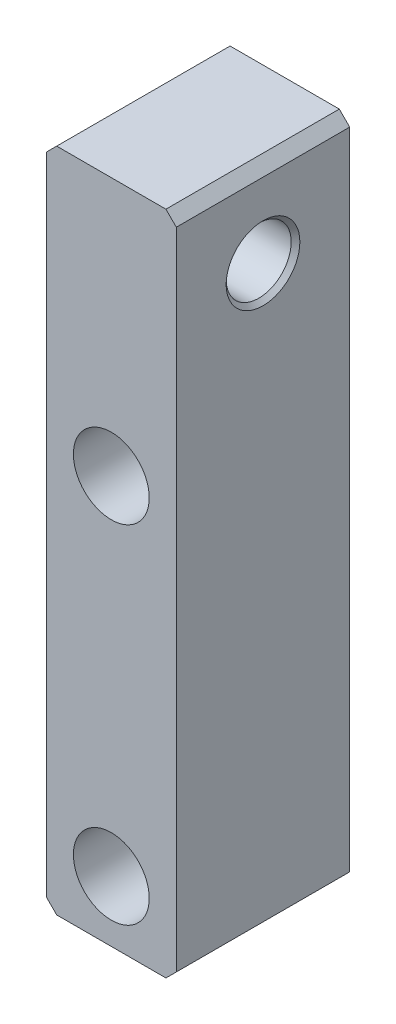
from build123d import *

# Parameters (mm, degrees)
BOSS_EXTRUDE1_DEPTH                              = 12.7
CBORE_FOR_1_4_SOCKET_HEAD_CAP_SCREW1_D           = 6.7564
CBORE_FOR_1_4_SOCKET_HEAD_CAP_SCREW1_DEPTH       = 25.4
CBORE_FOR_1_4_SOCKET_HEAD_CAP_SCREW1_CBORE_D     = 11.1125
CBORE_FOR_1_4_SOCKET_HEAD_CAP_SCREW1_CBORE_DEPTH = 9.652


with BuildPart() as part:
    # Sketch6 → Boss-Extrude1 (new body, symmetric)
    with BuildSketch(Plane.XY):
        Polygon((-8.001, 88.646), (8.001, 88.646), (9.525, 87.122), (9.525, -7.366), (8.001, -8.89), (-8.001, -8.89), (-9.525, -7.366), (-9.525, 87.122), align=None)
    extrude(amount=BOSS_EXTRUDE1_DEPTH, both=True)

    # Sketch11 → 3/8-16 Tapped Hole1 (revolve, cut)
    with BuildSketch(Plane(origin=(9.525, 76.2, 0), x_dir=(0, 0, -1), z_dir=(0, 1, 0))):
        Polygon((0, 0), (0, 19.05), (5.3975, 19.05), (4.7625, 18.415), (4.7625, 0.635), (5.3975, 0), align=None)
    revolve(axis=Axis((15.875, 76.2, 0), (-1, 0, 0)), mode=Mode.SUBTRACT)

    # CBORE for 1/4 Socket Head Cap Screw1
    with Locations(Plane.XY.offset(12.7)):
        with Locations((0, 0), (0, 50.8)):
            CounterBoreHole(CBORE_FOR_1_4_SOCKET_HEAD_CAP_SCREW1_D / 2, CBORE_FOR_1_4_SOCKET_HEAD_CAP_SCREW1_CBORE_D / 2, CBORE_FOR_1_4_SOCKET_HEAD_CAP_SCREW1_CBORE_DEPTH, depth=CBORE_FOR_1_4_SOCKET_HEAD_CAP_SCREW1_DEPTH)


solid = part.part
